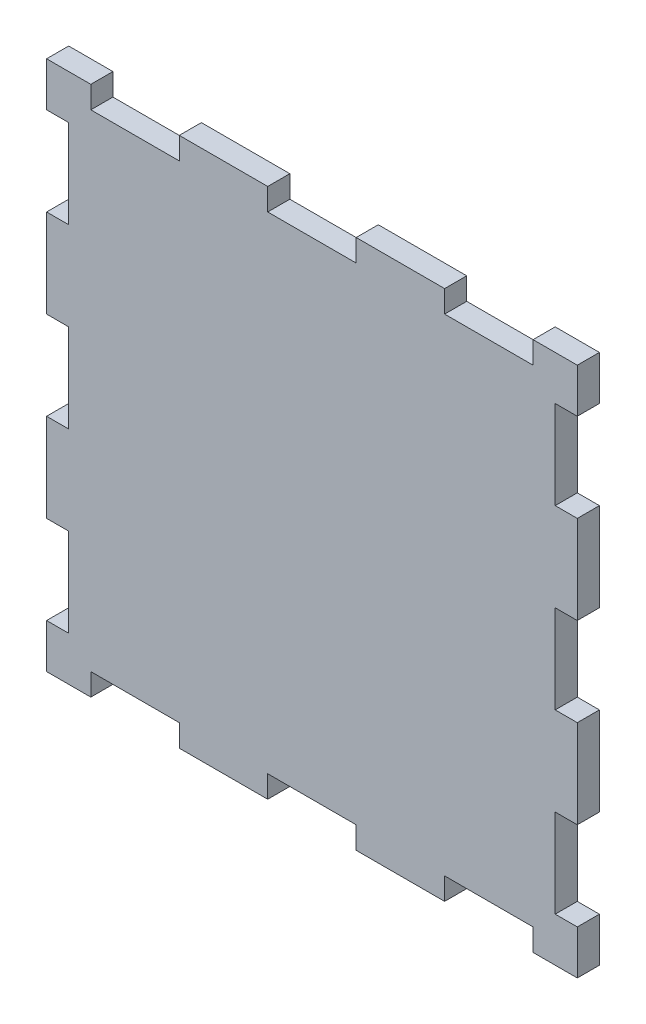
from build123d import *

# Parameters (mm, degrees)
SKETCH1_W            = 76.2
SKETCH1_H            = 76.2
EXTRUDE1_DEPTH       = 3.175
SKETCH3_W            = 3.175
SKETCH3_H            = 12.7
CUT_EXTRUDE1_DEPTH   = 3.175
LPATTERN1_COUNT      = 3
LPATTERN1_PITCH      = 25.4
LPATTERN1_COUNT_DIR2 = 2
LPATTERN1_PITCH_DIR2 = 73.025
SKETCH4_W            = 12.7
SKETCH4_H            = 3.175
CUT_EXTRUDE2_DEPTH   = 3.175
LPATTERN2_COUNT      = 3
LPATTERN2_PITCH      = 25.4
LPATTERN2_COUNT_DIR2 = 2
LPATTERN2_PITCH_DIR2 = 73.025


with BuildPart() as part:
    # Sketch1 → Extrude1 (new body)
    with BuildSketch(Plane.XY):
        with Locations((38.1, 38.1)):
            Rectangle(SKETCH1_W, SKETCH1_H)
    extrude(amount=EXTRUDE1_DEPTH)

    # Sketch3 → Cut-Extrude1 (cut)
    with BuildSketch(Plane.XY.offset(3.175)):
        with Locations((74.6125, 63.5)):
            Rectangle(SKETCH3_W, SKETCH3_H)
    cut_extrude1 = extrude(amount=-CUT_EXTRUDE1_DEPTH, mode=Mode.SUBTRACT)

    # LPattern1: Cut-Extrude1 3 × 2
    with Locations(*[(-j * LPATTERN1_PITCH_DIR2, -i * LPATTERN1_PITCH, 0) for i in range(LPATTERN1_COUNT) for j in range(LPATTERN1_COUNT_DIR2) if (i, j) != (0, 0)]):
        add(cut_extrude1, mode=Mode.SUBTRACT)

    # Sketch4 → Cut-Extrude2 (cut)
    with BuildSketch(Plane.XY.offset(3.175)):
        with Locations((63.5, 74.6125)):
            Rectangle(SKETCH4_W, SKETCH4_H)
    cut_extrude2 = extrude(amount=-CUT_EXTRUDE2_DEPTH, mode=Mode.SUBTRACT)

    # LPattern2: Cut-Extrude2 3 × 2
    with Locations(*[(-i * LPATTERN2_PITCH, -j * LPATTERN2_PITCH_DIR2, 0) for i in range(LPATTERN2_COUNT) for j in range(LPATTERN2_COUNT_DIR2) if (i, j) != (0, 0)]):
        add(cut_extrude2, mode=Mode.SUBTRACT)


solid = part.part
